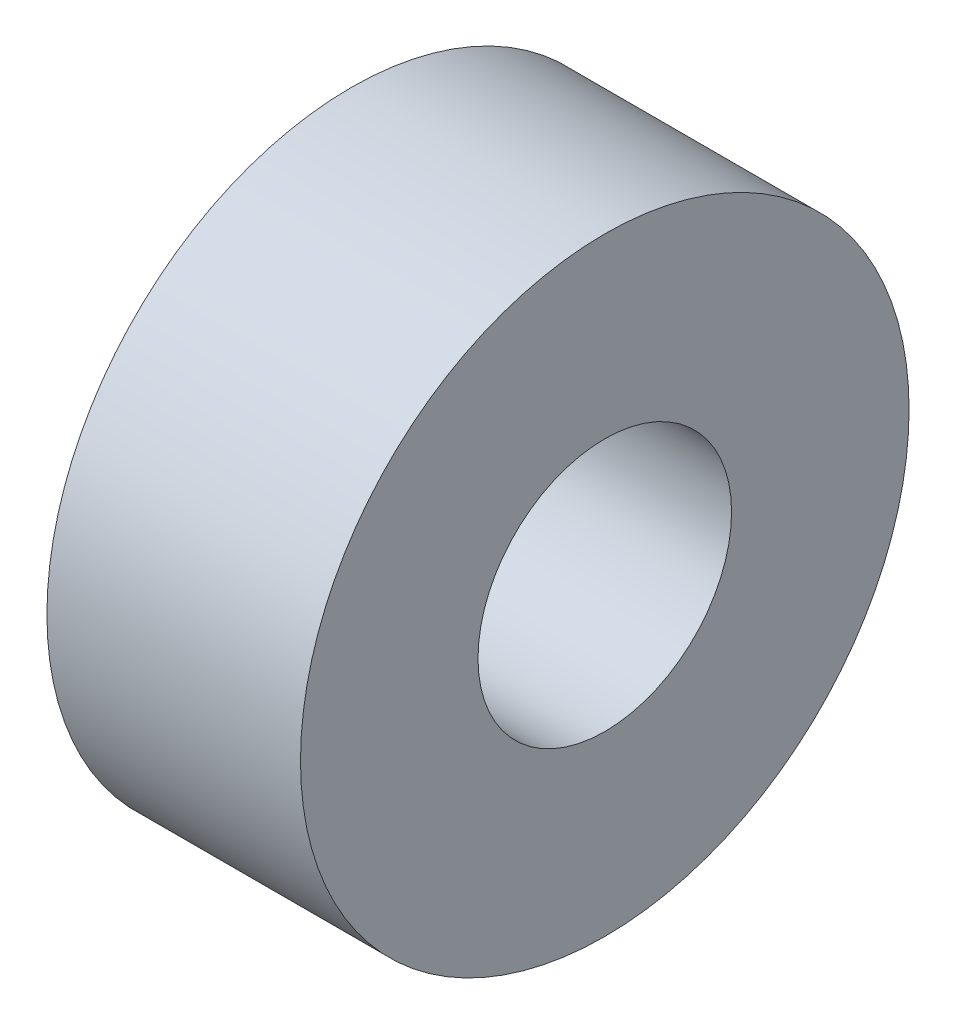
from build123d import *

# Parameters (mm, degrees)
SKETCH_1_R      = 6
SKETCH_1_R_2    = 2.5
EXTRUDE_1_DEPTH = 5


with BuildPart() as part:
    # 草图1 → 凸台-拉伸1 (new body)
    with BuildSketch(Plane(origin=(0, 0, 0), x_dir=(0, 0, -1), z_dir=(1, 0, 0))):
        Circle(SKETCH_1_R)
        Circle(SKETCH_1_R_2, mode=Mode.SUBTRACT)
    extrude(amount=EXTRUDE_1_DEPTH)


solid = part.part
